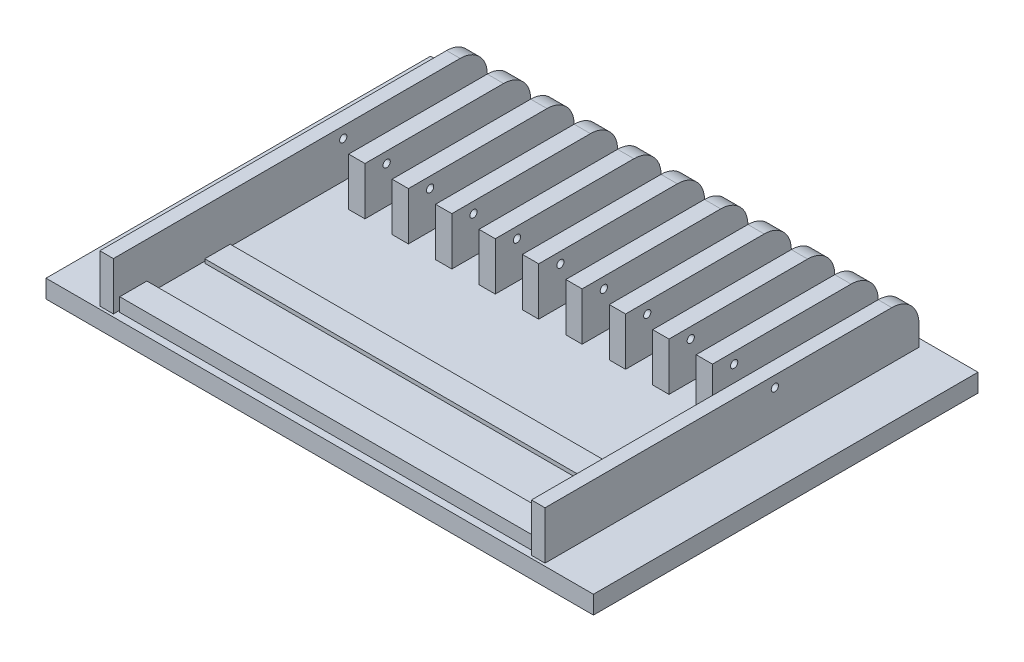
from build123d import *

# Parameters (mm, degrees)
SKETCH1_W           = 605
SKETCH1_H           = 425
BOSS_EXTRUDE1_DEPTH = 20
BOSS_EXTRUDE2_DEPTH = 246
SKETCH3_W           = 30
SKETCH3_H           = 53
CUT_EXTRUDE1_DEPTH  = 423
SKETCH4_R           = 4
CUT_EXTRUDE2_DEPTH  = 549.5
SKETCH5_W           = 230
SKETCH5_H           = 53
CUT_EXTRUDE3_DEPTH  = 220
SKETCH6_W           = 458
SKETCH6_H           = 30
BOSS_EXTRUDE3_DEPTH = 15
SKETCH7_W           = 458
SKETCH7_H           = 28
BOSS_EXTRUDE4_DEPTH = 4.3


with BuildPart() as part:
    # Sketch1 → Boss-Extrude1 (new body)
    with BuildSketch(Plane(origin=(0, 0, 0), x_dir=(1, 0, 0), z_dir=(0, 1, 0))):
        Rectangle(SKETCH1_W, SKETCH1_H)
    extrude(amount=-BOSS_EXTRUDE1_DEPTH)

    # Sketch2 → Boss-Extrude2 (add, symmetric)
    with BuildSketch(Plane(origin=(0, 0, 0), x_dir=(0, 0, -1), z_dir=(1, 0, 0))):
        with BuildLine():
            Line((203.7, 0), (-209.5, 0))
            Line((-209.5, 0), (-209.5, 53))
            Line((-209.5, 53), (173.7, 53))
            ThreePointArc((173.7, 53), (194.913203436, 44.213203436), (203.7, 23))
            Line((203.7, 23), (203.7, 0))
        make_face()
    extrude(amount=BOSS_EXTRUDE2_DEPTH, both=True)

    # Sketch3 → Cut-Extrude1 (cut, through all)
    with BuildSketch(Plane.XY.offset(209.5)):
        with Locations((-216, 26.5)):
            Rectangle(SKETCH3_W, SKETCH3_H)
        with Locations((-168, 26.5)):
            Rectangle(SKETCH3_W, SKETCH3_H)
        with Locations((-120, 26.5)):
            Rectangle(SKETCH3_W, SKETCH3_H)
        with Locations((-72, 26.5)):
            Rectangle(SKETCH3_W, SKETCH3_H)
        with Locations((-24, 26.5)):
            Rectangle(SKETCH3_W, SKETCH3_H)
        with Locations((24, 26.5)):
            Rectangle(SKETCH3_W, SKETCH3_H)
        with Locations((72, 26.5)):
            Rectangle(SKETCH3_W, SKETCH3_H)
        with Locations((120, 26.5)):
            Rectangle(SKETCH3_W, SKETCH3_H)
        with Locations((168, 26.5)):
            Rectangle(SKETCH3_W, SKETCH3_H)
        with Locations((216, 26.5)):
            Rectangle(SKETCH3_W, SKETCH3_H)
    extrude(amount=-CUT_EXTRUDE1_DEPTH, mode=Mode.SUBTRACT)

    # Sketch4 → Cut-Extrude2 (cut, through all)
    with BuildSketch(Plane.ZY.offset(246)):
        with Locations((-44.5, 41)):
            Circle(SKETCH4_R)
    extrude(amount=-CUT_EXTRUDE2_DEPTH, mode=Mode.SUBTRACT)

    # Sketch5 → Cut-Extrude3 (cut, symmetric)
    with BuildSketch(Plane(origin=(0, 0, 0), x_dir=(0, 0, -1), z_dir=(1, 0, 0))):
        with Locations((-94.5, 26.5)):
            Rectangle(SKETCH5_W, SKETCH5_H)
    extrude(amount=CUT_EXTRUDE3_DEPTH, both=True, mode=Mode.SUBTRACT)

    # Sketch6 → Boss-Extrude3 (add)
    with BuildSketch(Plane(origin=(0, 0, 0), x_dir=(1, 0, 0), z_dir=(0, 1, 0))):
        with Locations((0, -189.5)):
            Rectangle(SKETCH6_W, SKETCH6_H)
    extrude(amount=BOSS_EXTRUDE3_DEPTH)

    # Sketch7 → Boss-Extrude4 (add)
    with BuildSketch(Plane(origin=(0, 0, 0), x_dir=(1, 0, 0), z_dir=(0, 1, 0))):
        with Locations((0, -96.5)):
            Rectangle(SKETCH7_W, SKETCH7_H)
    extrude(amount=BOSS_EXTRUDE4_DEPTH)


solid = part.part
